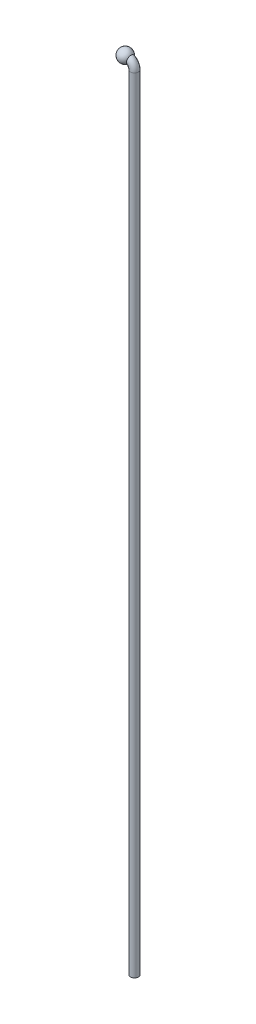
from build123d import *

# Parameters (mm, degrees)
SKETCH1_R           = 0.15
SKETCH6_R           = 0.2
BOSS_EXTRUDE1_DEPTH = 0.15


with BuildPart() as part:
    # Sweep1: sweep along a path in Sketch3
    with BuildLine(Plane.XY) as sweep1_path:
        Line((0, 0), (0.05, 0))
        ThreePointArc((0.05, 0), (0.262132034, -0.087867966), (0.35, -0.3))
        Line((0.35, -0.3), (0.35, -30))
    # Sketch1 → Sweep1 (sweep)
    with BuildSketch(Plane(origin=(0, 0, 0), x_dir=(0, 0, -1), z_dir=(1, 0, 0))):
        Circle(SKETCH1_R)
    sweep(path=sweep1_path.line)

    # Sketch6 → Boss-Extrude1 (add)
    with BuildSketch(Plane.ZY):
        Circle(SKETCH6_R)
    extrude(amount=-BOSS_EXTRUDE1_DEPTH)

    # Sketch4 → Revolve2 (revolve)
    with BuildSketch(Plane.ZY):
        with BuildLine():
            Line((0, 0.25), (0, -0.25))
            ThreePointArc((0, -0.25), (-0.25, 0), (0, 0.25))
        make_face()
    revolve(axis=Axis((0, 0.25, 0), (0, -1, 0)))


solid = part.part
